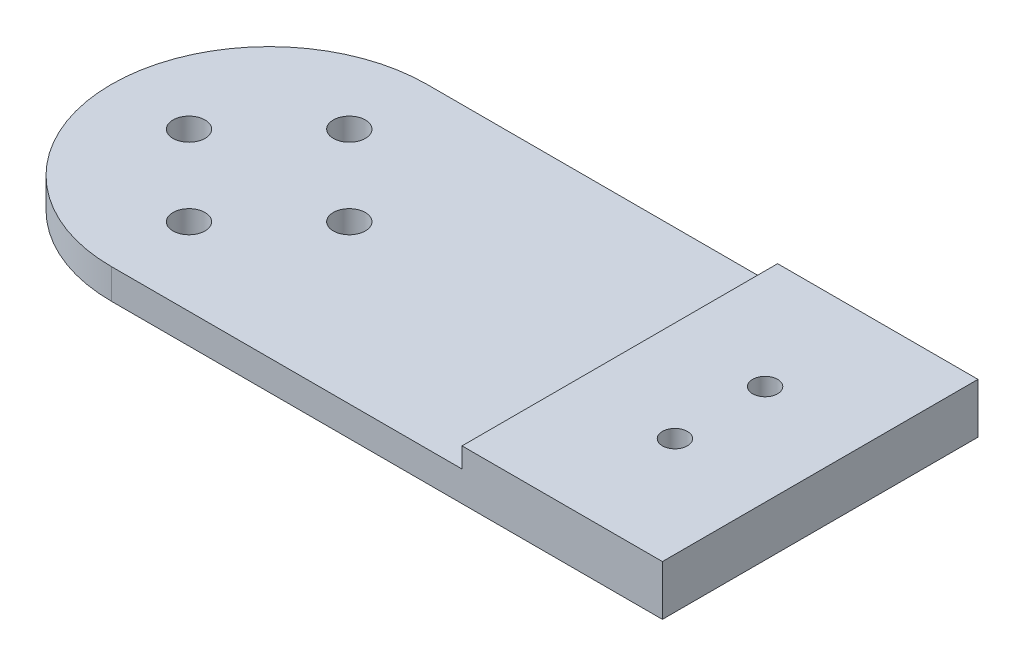
from build123d import *

# Parameters (mm, degrees)
SKETCH_1_R          = 15.75
SKETCH_1_R_2        = 1.6
EXTRUDE_1_DEPTH     = 3
EXTRUDE_2_DEPTH     = 3
SKETCH_3_W          = 20
SKETCH_3_H          = 31.5
EXTRUDE_3_DEPTH     = 5
SKETCH_4_R          = 1.25
CUT_EXTRUDE_1_DEPTH = 10


with BuildPart() as part:
    # 草图1 → 凸台-拉伸1 (new body)
    with BuildSketch(Plane(origin=(0, 0, 0), x_dir=(1, 0, 0), z_dir=(0, 1, 0))):
        Circle(SKETCH_1_R)
        with Locations((0, 8)):
            Circle(SKETCH_1_R_2, mode=Mode.SUBTRACT)
        with Locations((8, 0)):
            Circle(SKETCH_1_R_2, mode=Mode.SUBTRACT)
        with Locations((0, -8)):
            Circle(SKETCH_1_R_2, mode=Mode.SUBTRACT)
        with Locations((-8, 0)):
            Circle(SKETCH_1_R_2, mode=Mode.SUBTRACT)
    extrude(amount=EXTRUDE_1_DEPTH)

    # 草图2 → 凸台-拉伸2 (add)
    with BuildSketch(Plane.XZ):
        with BuildLine():
            Line((0, 15.75), (55, 15.75))
            Line((55, 15.75), (55, -15.75))
            Line((55, -15.75), (0, -15.75))
            ThreePointArc((0, -15.75), (15.75, 0), (0, 15.75))
        make_face()
    extrude(amount=-EXTRUDE_2_DEPTH)

    # 草图3 → 凸台-拉伸3 (add)
    with BuildSketch(Plane.XZ):
        with Locations((45, 0)):
            Rectangle(SKETCH_3_W, SKETCH_3_H)
    extrude(amount=-EXTRUDE_3_DEPTH)

    # 草图4 → 切除-拉伸1 (cut)
    with BuildSketch(Plane(origin=(0, 5, 0), x_dir=(1, 0, 0), z_dir=(0, 1, 0))):
        with Locations((45, 4.5)):
            Circle(SKETCH_4_R)
        with Locations((45, -4.5)):
            Circle(SKETCH_4_R)
    extrude(amount=-CUT_EXTRUDE_1_DEPTH, mode=Mode.SUBTRACT)


solid = part.part
